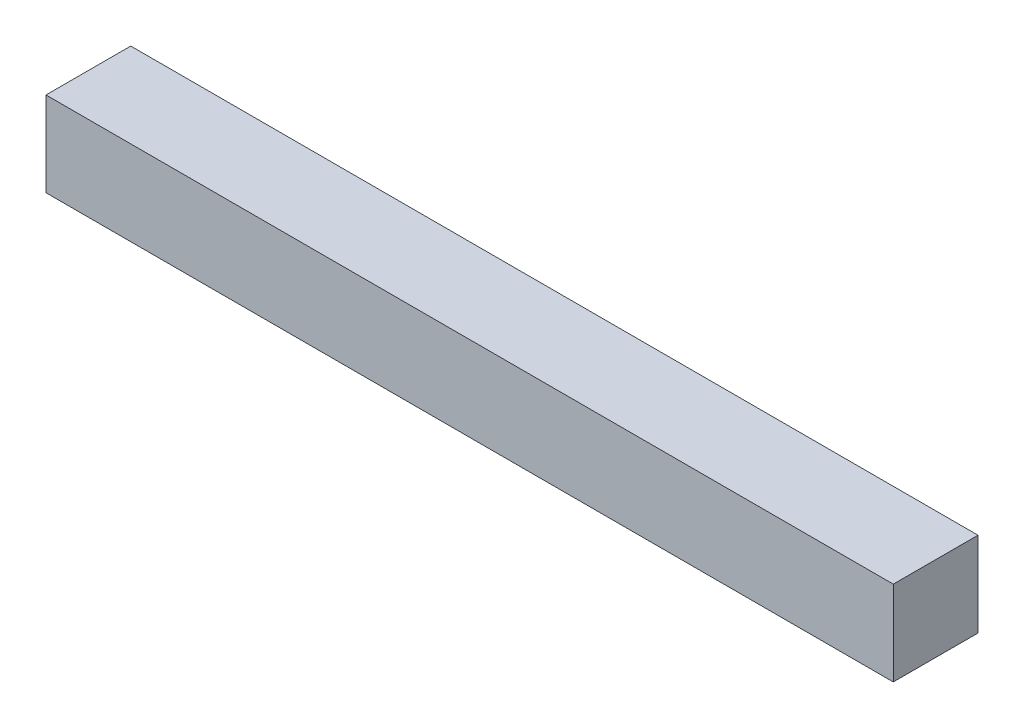
from build123d import *

# Parameters (mm, degrees)
SKETCH1_W           = 150
SKETCH1_H           = 15
BOSS_EXTRUDE1_DEPTH = 15
SKETCH2_R           = 4.8125
CUT_EXTRUDE1_DEPTH  = 140


with BuildPart() as part:
    # Sketch1 → Boss-Extrude1 (new body)
    with BuildSketch(Plane(origin=(0, 0, 0), x_dir=(1, 0, 0), z_dir=(0, 1, 0))):
        Rectangle(SKETCH1_W, SKETCH1_H)
    extrude(amount=BOSS_EXTRUDE1_DEPTH)

    # Sketch2 → Cut-Extrude1 (cut)
    with BuildSketch(Plane.ZY.offset(75)):
        with Locations((0, 7.5)):
            Circle(SKETCH2_R)
    extrude(amount=-CUT_EXTRUDE1_DEPTH, mode=Mode.SUBTRACT)


solid = part.part
